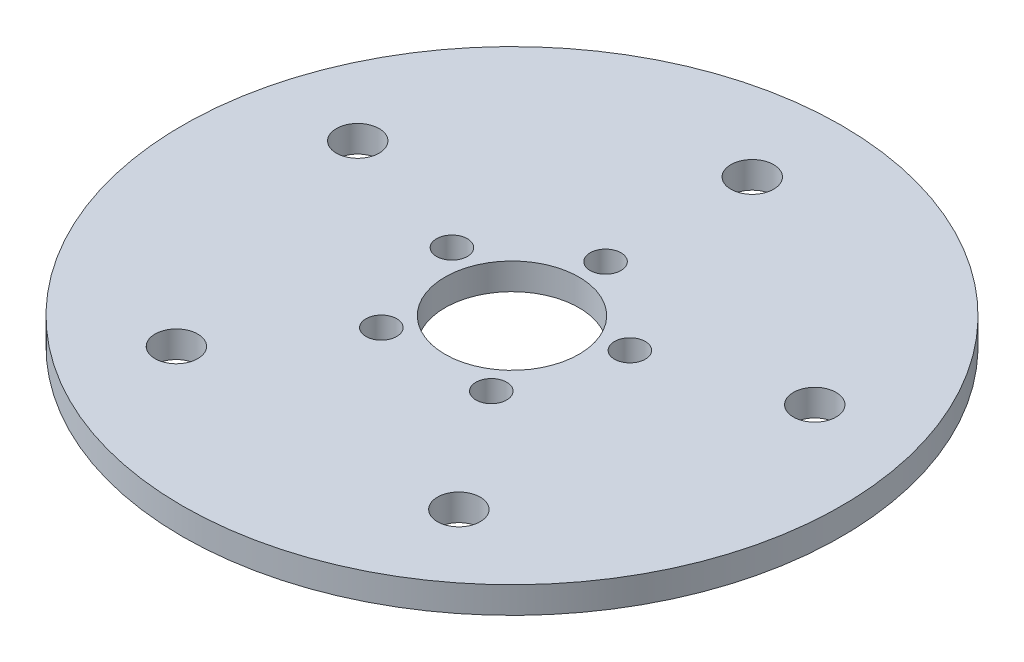
from build123d import *

# Parameters (mm, degrees)
SKETCH1_R           = 39.37
BOSS_EXTRUDE1_DEPTH = 3.175
SKETCH2_R           = 8.001
SKETCH2_R_2         = 1.8415
SKETCH2_R_3         = 2.5527
CUT_EXTRUDE1_DEPTH  = 4.175


with BuildPart() as part:
    # Sketch1 → Boss-Extrude1 (new body)
    with BuildSketch(Plane(origin=(0, 807.11642412, 0), x_dir=(-1, 0, 0), z_dir=(0, 1, 0))):
        Circle(SKETCH1_R)
    extrude(amount=-BOSS_EXTRUDE1_DEPTH)

    # Sketch2 → Cut-Extrude1 (cut, through all)
    with BuildSketch(Plane(origin=(0, 807.11642412, 0), x_dir=(1, 0, 0), z_dir=(0, 1, 0))):
        Circle(SKETCH2_R)
        with Locations((0, 11.176)):
            Circle(SKETCH2_R_2)
        with Locations((10.629007626, 3.453573929)):
            Circle(SKETCH2_R_2)
        with Locations((6.56908798, -9.041573929)):
            Circle(SKETCH2_R_2)
        with Locations((-6.56908798, -9.041573929)):
            Circle(SKETCH2_R_2)
        with Locations((-10.629007626, 3.453573929)):
            Circle(SKETCH2_R_2)
        with Locations((0, 28.702)):
            Circle(SKETCH2_R_3)
        with Locations((27.297224131, 8.869405773)):
            Circle(SKETCH2_R_3)
        with Locations((16.870612311, -23.220405773)):
            Circle(SKETCH2_R_3)
        with Locations((-16.870612311, -23.220405773)):
            Circle(SKETCH2_R_3)
        with Locations((-27.297224131, 8.869405773)):
            Circle(SKETCH2_R_3)
    extrude(amount=-CUT_EXTRUDE1_DEPTH, mode=Mode.SUBTRACT)


solid = part.part
